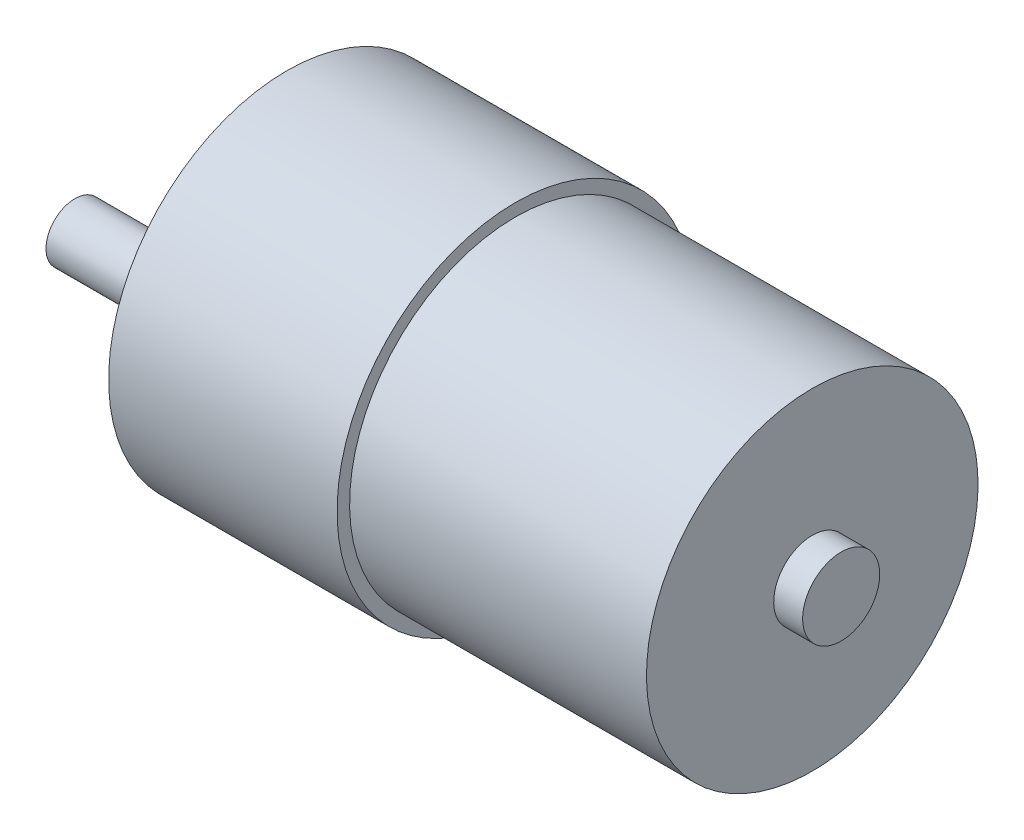
from build123d import *

# Parameters (mm, degrees)
SKETCH1_W           = 23.7
SKETCH1_H           = 18.5
SKETCH1_W_2         = 3
SKETCH1_H_2         = 4
SKETCH2_R           = 6.5
BOSS_EXTRUDE1_DEPTH = 7
SKETCH3_R           = 3
BOSS_EXTRUDE2_DEPTH = 15


with BuildPart() as part:
    # Sketch1 → Revolve1 (revolve)
    with BuildSketch(Plane.XY):
        with Locations((-11.85, 9.25)):
            Rectangle(SKETCH1_W, SKETCH1_H)
        Polygon((30.8, 17.2), (0, 17.2), (0, 0), (30.8, 0), (30.8, 4), align=None)
        with Locations((32.3, 2)):
            Rectangle(SKETCH1_W_2, SKETCH1_H_2)
    revolve(axis=Axis((30.8, 0, 0), (-1, 0, 0)))

    # Sketch2 → Boss-Extrude1 (add)
    with BuildSketch(Plane.ZY.offset(23.7)):
        with Locations((0, -7)):
            Circle(SKETCH2_R)
    extrude(amount=BOSS_EXTRUDE1_DEPTH)

    # Sketch3 → Boss-Extrude2 (add)
    with BuildSketch(Plane.ZY.offset(30.7)):
        with Locations((0, -7)):
            Circle(SKETCH3_R)
    extrude(amount=BOSS_EXTRUDE2_DEPTH)


solid = part.part
